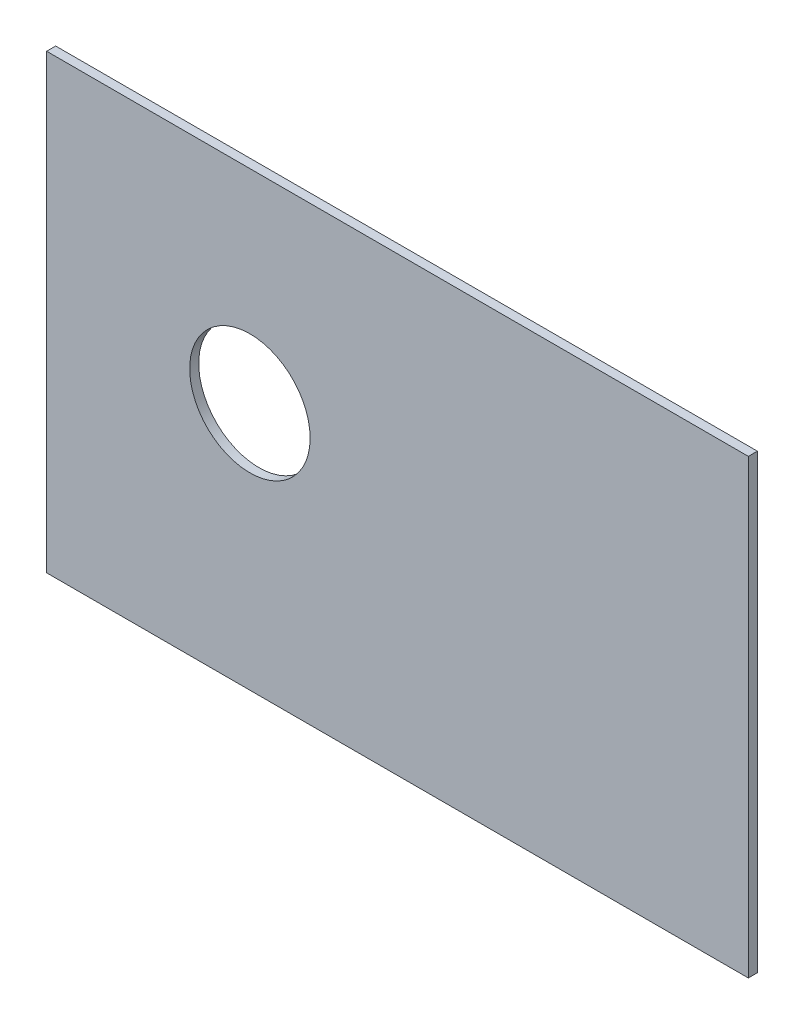
from build123d import *

# Parameters (mm, degrees)
SKETCH1_W           = 233
SKETCH1_H           = 150
BOSS_EXTRUDE1_DEPTH = 3
SKETCH2_R           = 20
CUT_EXTRUDE3_DEPTH  = 4


with BuildPart() as part:
    # Sketch1 → Boss-Extrude1 (new body)
    with BuildSketch(Plane.XY):
        with Locations((0, 29)):
            Rectangle(SKETCH1_W, SKETCH1_H)
    extrude(amount=BOSS_EXTRUDE1_DEPTH)

    # Sketch2 → Cut-Extrude3 (cut, through all)
    with BuildSketch(Plane.XY.offset(3)):
        with Locations((-49, 36.5)):
            Circle(SKETCH2_R)
    extrude(amount=-CUT_EXTRUDE3_DEPTH, mode=Mode.SUBTRACT)


solid = part.part
